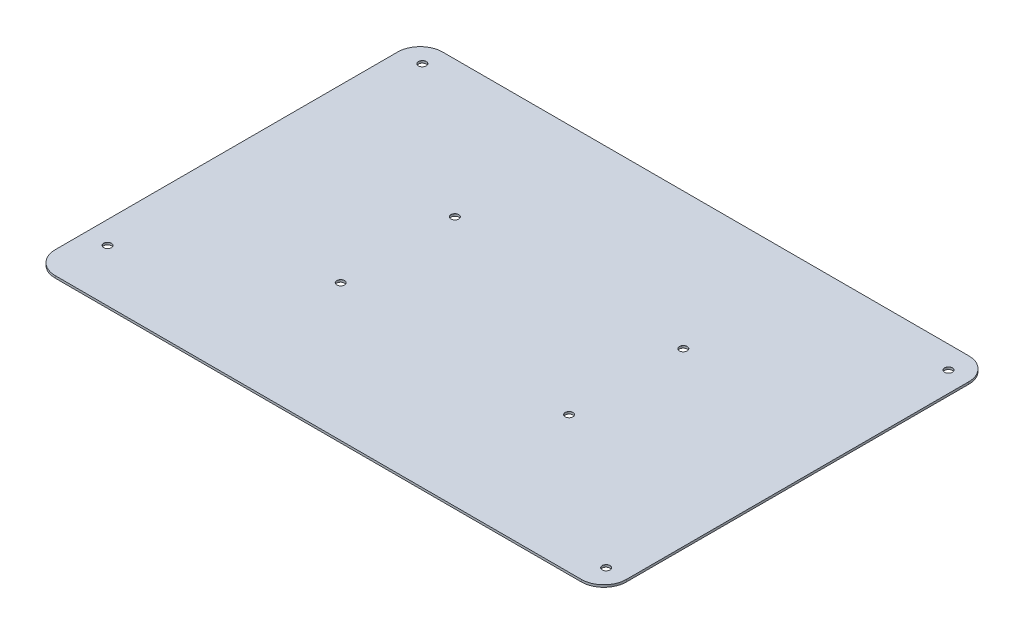
from build123d import *

# Parameters (mm, degrees)
SKETCH1_W                     = 254
SKETCH1_H                     = 172.27
BOSS_EXTRUDE1_DEPTH           = 1
FILLET1_R                     = 10
M3_CLEARANCE_HOLE1_AT_2_COUNT = 2
M3_CLEARANCE_HOLE1_AT_2_PITCH = 140
M3_CLEARANCE_HOLE1_AT_3_COUNT = 2
M3_CLEARANCE_HOLE1_AT_3_PITCH = 280.564953086
M3_CLEARANCE_HOLE1_AT_4_COUNT = 2
M3_CLEARANCE_HOLE1_AT_4_PITCH = 235.00212765
M3_CLEARANCE_HOLE1_AT_5_COUNT = 2
M3_CLEARANCE_HOLE1_AT_5_PITCH = 122.048622381
M3_CLEARANCE_HOLE1_AT_6_COUNT = 2
M3_CLEARANCE_HOLE1_AT_6_PITCH = 196.647568571
M3_CLEARANCE_HOLE1_AT_7_COUNT = 2
M3_CLEARANCE_HOLE1_AT_7_PITCH = 84.017559028
M3_CLEARANCE_HOLE1_AT_8_COUNT = 2
M3_CLEARANCE_HOLE1_AT_8_PITCH = 175.594277313


with BuildPart() as part:
    # Sketch1 → Boss-Extrude1 (new body)
    with BuildSketch(Plane(origin=(0, 0, 0), x_dir=(1, 0, 0), z_dir=(0, 1, 0))):
        Rectangle(SKETCH1_W, SKETCH1_H)
    extrude(amount=BOSS_EXTRUDE1_DEPTH)

    # Fillet1
    fillet1_edges = [part.edges().sort_by_distance(p)[0] for p in [
        (127, 0.5, 86.135),
        (-127, 0.5, 86.135),
        (-127, 0.5, -86.135),
        (127, 0.5, -86.135),
    ]]
    fillet(fillet1_edges, radius=FILLET1_R)

    # Sketch3 → M3 Clearance Hole1 (revolve, cut)
    with BuildSketch(Plane(origin=(-117, 1, -77.135), x_dir=(0, 0, 1), z_dir=(1, 0, 0))):
        Polygon((0, 0), (0, 1), (1.7, 1), (1.7, 0.025), (1.725, 0), align=None)
    m3_clearance_hole1 = revolve(axis=Axis((-117, 7.35, -77.135), (0, -1, 0)), mode=Mode.SUBTRACT)

    # M3 Clearance Hole1 at 2: M3 Clearance Hole1 ×2
    with Locations(*[(0, 0, i * M3_CLEARANCE_HOLE1_AT_2_PITCH) for i in range(1, M3_CLEARANCE_HOLE1_AT_2_COUNT)]):
        add(m3_clearance_hole1, mode=Mode.SUBTRACT)

    # M3 Clearance Hole1 at 3: M3 Clearance Hole1 ×2
    with Locations(*[Vector(0.837595706, 0, 0.546290612) * (i * M3_CLEARANCE_HOLE1_AT_3_PITCH) for i in range(1, M3_CLEARANCE_HOLE1_AT_3_COUNT)]):
        add(m3_clearance_hole1, mode=Mode.SUBTRACT)

    # M3 Clearance Hole1 at 4: M3 Clearance Hole1 ×2
    with Locations(*[Vector(0.999990946, 0, 0.004255281) * (i * M3_CLEARANCE_HOLE1_AT_4_PITCH) for i in range(1, M3_CLEARANCE_HOLE1_AT_4_COUNT)]):
        add(m3_clearance_hole1, mode=Mode.SUBTRACT)

    # M3 Clearance Hole1 at 5: M3 Clearance Hole1 ×2
    with Locations(*[Vector(0.542406778, 0, 0.840115996) * (i * M3_CLEARANCE_HOLE1_AT_5_PITCH) for i in range(1, M3_CLEARANCE_HOLE1_AT_5_COUNT)]):
        add(m3_clearance_hole1, mode=Mode.SUBTRACT)

    # M3 Clearance Hole1 at 6: M3 Clearance Hole1 ×2
    with Locations(*[Vector(0.853303202, 0, 0.521415041) * (i * M3_CLEARANCE_HOLE1_AT_6_PITCH) for i in range(1, M3_CLEARANCE_HOLE1_AT_6_COUNT)]):
        add(m3_clearance_hole1, mode=Mode.SUBTRACT)

    # M3 Clearance Hole1 at 7: M3 Clearance Hole1 ×2
    with Locations(*[Vector(0.787930532, 0, 0.61576414) * (i * M3_CLEARANCE_HOLE1_AT_7_PITCH) for i in range(1, M3_CLEARANCE_HOLE1_AT_7_COUNT)]):
        add(m3_clearance_hole1, mode=Mode.SUBTRACT)

    # M3 Clearance Hole1 at 8: M3 Clearance Hole1 ×2
    with Locations(*[Vector(0.955612008, 0, 0.294628053) * (i * M3_CLEARANCE_HOLE1_AT_8_PITCH) for i in range(1, M3_CLEARANCE_HOLE1_AT_8_COUNT)]):
        add(m3_clearance_hole1, mode=Mode.SUBTRACT)


solid = part.part
